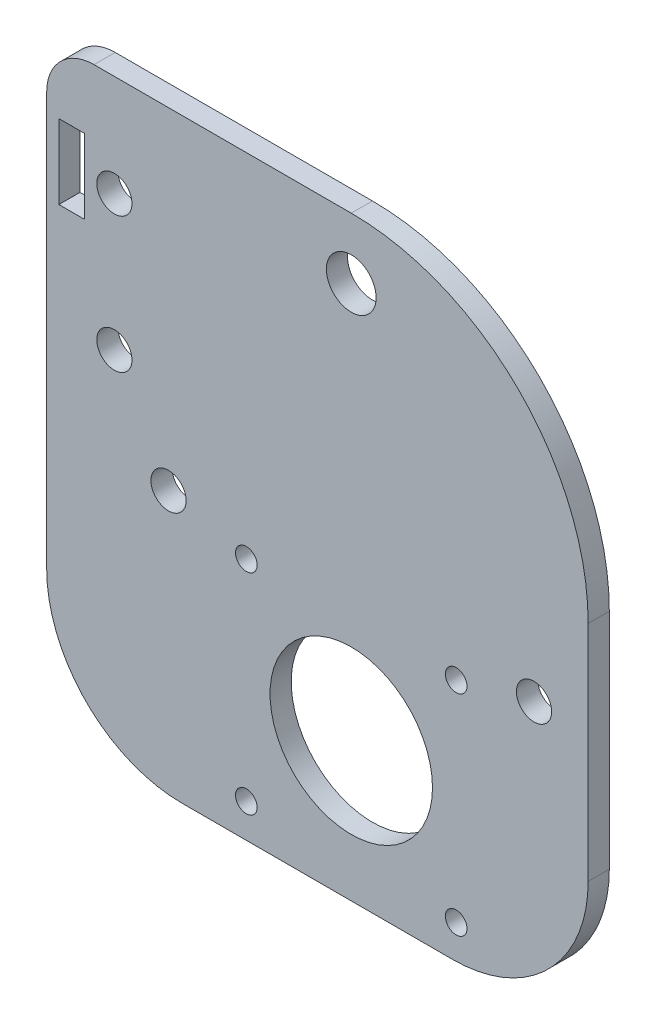
from build123d import *

# Parameters (mm, degrees)
MODEL_R             = 2.6
MODEL_R_2           = 12
MODEL_R_3           = 1.6
MODEL_R_4           = 3.675
MODEL_W             = 3.760660172
MODEL_H             = 11
BOSS_EXTRUDE1_DEPTH = 3.125


with BuildPart() as part:
    # Model → Boss-Extrude1 (new body)
    with BuildSketch(Plane.XY):
        with BuildLine():
            Line((80, 20), (80, 53))
            ThreePointArc((80, 53), (69.748737342, 77.748737342), (45, 88))
            Line((45, 88), (7, 88))
            ThreePointArc((7, 88), (2.050252532, 85.949747468), (0, 81))
            Line((0, 81), (0, 20))
            ThreePointArc((0, 20), (5.857864376, 5.857864376), (20, 0))
            Line((20, 0), (60, 0))
            ThreePointArc((60, 0), (74.142135624, 5.857864376), (80, 20))
        make_face()
        with Locations((10, 73)):
            Circle(MODEL_R, mode=Mode.SUBTRACT)
        with Locations((45, 20.5)):
            Circle(MODEL_R_2, mode=Mode.SUBTRACT)
        with Locations((18, 39)):
            Circle(MODEL_R, mode=Mode.SUBTRACT)
        with Locations((60.5, 36)):
            Circle(MODEL_R_3, mode=Mode.SUBTRACT)
        with Locations((29.5, 5)):
            Circle(MODEL_R_3, mode=Mode.SUBTRACT)
        with Locations((45, 79)):
            Circle(MODEL_R_4, mode=Mode.SUBTRACT)
        with Locations((10, 53)):
            Circle(MODEL_R, mode=Mode.SUBTRACT)
        with Locations((29.5, 36)):
            Circle(MODEL_R_3, mode=Mode.SUBTRACT)
        with Locations((60.5, 5)):
            Circle(MODEL_R_3, mode=Mode.SUBTRACT)
        with Locations((72, 39)):
            Circle(MODEL_R, mode=Mode.SUBTRACT)
        with Locations((3.680330086, 73)):
            Rectangle(MODEL_W, MODEL_H, mode=Mode.SUBTRACT)
    extrude(amount=BOSS_EXTRUDE1_DEPTH)


solid = part.part
